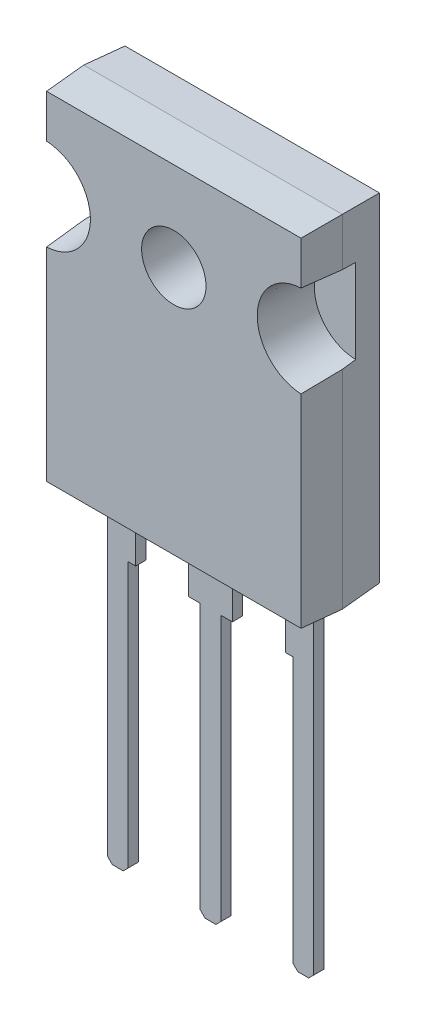
from build123d import *

# Parameters (mm, degrees)
SKETCH1_W                     = 15.500000000000002
SKETCH1_H                     = 20.5
BOSS_EXTRUDE1_DEPTH           = 2.35
BOSS_EXTRUDE1_TAPER           = 3.0000000000000067
BOSS_EXTRUDE1_OTHER_WAY_DEPTH = 2.35
BOSS_EXTRUDE1_OTHER_WAY_TAPER = 3.0000000000000067
SKETCH2_R                     = 1.9300000000000004
CUT_EXTRUDE1_DEPTH            = 14.682653417374864
SKETCH3_R                     = 2.7499999999999982
CUT_EXTRUDE2_DEPTH            = 3.2
CUT_EXTRUDE2_DRAFT            = -4.000000000000009
SKETCH3_R_2                   = 2.75
CUT_EXTRUDE2_PROFILE_2_DEPTH  = 3.2
CUT_EXTRUDE2_PROFILE_2_DRAFT  = -4.000000000000009
SKETCH4_R                     = 3.305
CUT_EXTRUDE3_DEPTH            = 0.001
BOSS_EXTRUDE2_DEPTH           = 0.61
CHAMFER1_SIZE                 = 0.3


with BuildPart() as part:
    # Sketch1 → Boss-Extrude1 (new body)
    with BuildSketch(Plane.XY):
        Rectangle(SKETCH1_W, SKETCH1_H)
    extrude(amount=BOSS_EXTRUDE1_DEPTH, taper=BOSS_EXTRUDE1_TAPER)

    # Sketch1 → Boss-Extrude1 other way (add)
    with BuildSketch(Plane.XY):
        Rectangle(SKETCH1_W, SKETCH1_H)
    extrude(amount=-BOSS_EXTRUDE1_OTHER_WAY_DEPTH, taper=BOSS_EXTRUDE1_OTHER_WAY_TAPER)

    # Sketch2 → Cut-Extrude1 (cut, through all)
    with BuildSketch(Plane.XY.offset(2.35)):
        with Locations((0, 4.790000000000001)):
            Circle(SKETCH2_R)
    extrude(amount=-CUT_EXTRUDE1_DEPTH, mode=Mode.SUBTRACT)


with BuildPart() as cut_extrude2_tool:
    # Sketch3 → Cut-Extrude2 (with draft: the straight prism first)
    with BuildSketch(Plane.XY.offset(2.35)):
        with Locations((7.75, 4.790000000000001)):
            Circle(SKETCH3_R)
    extrude(amount=-CUT_EXTRUDE2_DEPTH)
    # Cut-Extrude2: the draft: its side faces are tilted about the plane it starts from
    cut_extrude2_sides = [cut_extrude2_tool.faces().sort_by_distance(p)[0] for p in [
        (5, 4.79, 0.75),
    ]]
    draft(cut_extrude2_sides, Plane.XY.offset(2.35), CUT_EXTRUDE2_DRAFT)


with BuildPart() as part_1:
    add(part.part)

    # Cut-Extrude2: cut by cut_extrude2_tool
    add(cut_extrude2_tool.part, mode=Mode.SUBTRACT)


with BuildPart() as cut_extrude2_profile_2_tool:
    # Sketch3 → Cut-Extrude2 profile 2 (with draft: the straight prism first)
    with BuildSketch(Plane.XY.offset(2.35)):
        with Locations((-7.75, 4.790000000000001)):
            Circle(SKETCH3_R_2)
    extrude(amount=-CUT_EXTRUDE2_PROFILE_2_DEPTH)
    # Cut-Extrude2 profile 2: the draft: its side faces are tilted about the plane it starts from
    cut_extrude2_profile_2_sides = [cut_extrude2_profile_2_tool.faces().sort_by_distance(p)[0] for p in [
        (-10.5, 4.79, 0.75),
    ]]
    draft(cut_extrude2_profile_2_sides, Plane.XY.offset(2.35), CUT_EXTRUDE2_PROFILE_2_DRAFT)


with BuildPart() as part_2:
    add(part_1.part)

    # Cut-Extrude2 profile 2: cut by cut_extrude2_profile_2_tool
    add(cut_extrude2_profile_2_tool.part, mode=Mode.SUBTRACT)

    # Sketch4 → Cut-Extrude3 (cut)
    with BuildSketch(Plane(origin=(0, 0, -2.35), x_dir=(-1, 0, 0), z_dir=(0, 0, -1))):
        Polygon((-6.539115869693152, 8.755028571929065), (-5.095312145144818, 9.74), (-3.520299832613913, 9.74), (-3.520299832613913, 9.540000000000001), (3.520299832613913, 9.540000000000001), (3.520299832613913, 9.74), (4.827080405758514, 9.74), (6.2708841303068485, 8.755028571929065), (6.270884130306849, 1.9970301626645939), (6.07088413030685, 1.9970301626645939), (6.070884130306851, -3.3399999999999994), (-6.339115869693153, -3.3400000000000007), (-6.339115869693152, 1.9970301626645925), (-6.539115869693152, 1.997030162664592), align=None)
        with Locations((0, 4.790000000000001)):
            Circle(SKETCH4_R, mode=Mode.SUBTRACT)
    extrude(amount=-CUT_EXTRUDE3_DEPTH, mode=Mode.SUBTRACT)

    # Sketch6 → Boss-Extrude2 (add)
    with BuildSketch(Plane(origin=(0, 0, 0.14999999999999997), x_dir=(-1, 0, 0), z_dir=(0, 0, -1))):
        Polygon((-6.1850000000000005, -10.126841718684854), (-6.184999999999995, -30.249999999999993), (-4.934999999999998, -30.249999999999993), (-4.934999999999998, -14.049999999999999), (-4.484999999999999, -14.049999999999999), (-4.485, -10.126841718684854), align=None)
        Polygon((4.485000000000002, -10.126841718684853), (6.185000000000002, -10.126841718684853), (6.185000000000002, -30.249999999999993), (4.935000000000004, -30.249999999999993), (4.935000000000001, -14.049999999999997), (4.485000000000003, -14.049999999999997), align=None)
        Polygon((-1.3099999999999987, -10.126841718684854), (1.3100000000000005, -10.126841718684854), (1.3100000000000016, -14.05), (0.6250000000000014, -14.05), (0.6250000000000027, -30.249999999999993), (-0.624999999999995, -30.249999999999993), (-0.6249999999999972, -14.049999999999999), (-1.3099999999999983, -14.049999999999999), align=None)
    extrude(amount=BOSS_EXTRUDE2_DEPTH)

    # Chamfer1
    chamfer1_edges = [part_2.edges().sort_by_distance(p)[0] for p in [
        (6.184999999999995, -30.249999999999993, -0.15500000000000003),
        (4.934999999999998, -30.249999999999993, -0.15500000000000003),
        (-4.935000000000004, -30.249999999999993, -0.15500000000000003),
        (-6.185000000000002, -30.249999999999993, -0.15500000000000003),
        (0.624999999999995, -30.249999999999993, -0.15500000000000003),
        (-0.6250000000000027, -30.249999999999993, -0.15500000000000003),
    ]]
    chamfer(chamfer1_edges, length=CHAMFER1_SIZE)


solid = part_2.part
